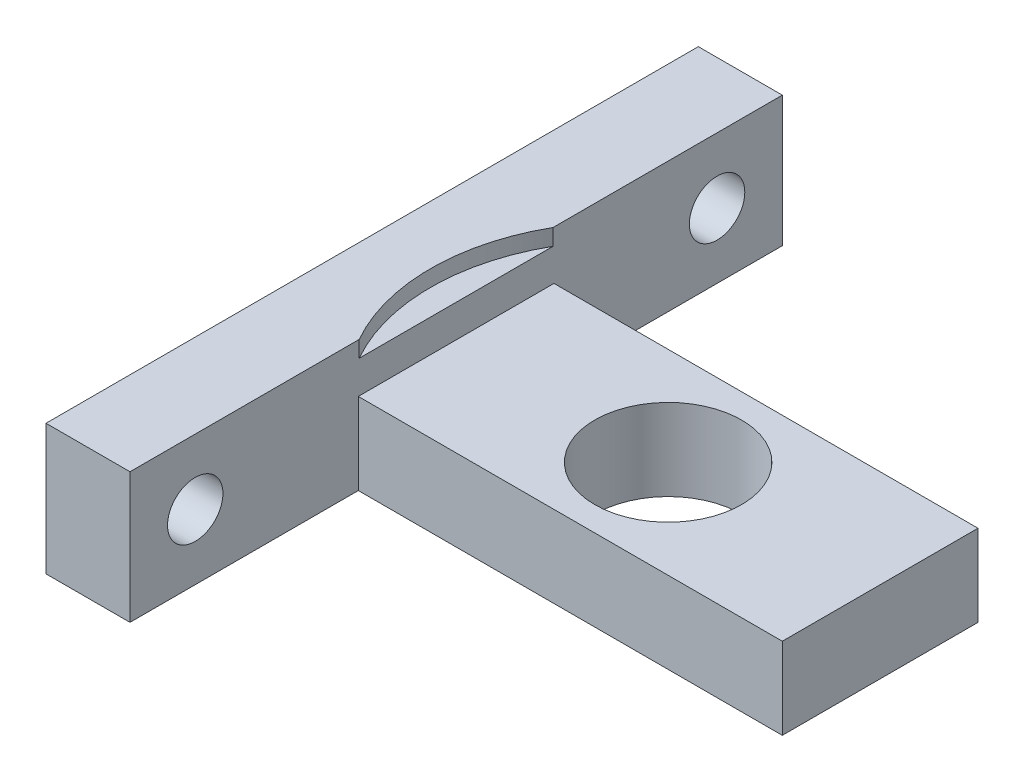
from build123d import *

# Parameters (mm, degrees)
CROQUIS1_W              = 5.15
CROQUIS1_H              = 40
SALIENTE_EXTRUIR1_DEPTH = 8
CROQUIS2_R              = 1.7
CORTAR_EXTRUIR1_DEPTH   = 11
CROQUIS3_W              = 26
CROQUIS3_H              = 12
CROQUIS3_R              = 4.5
SALIENTE_EXTRUIR2_DEPTH = 5
CROQUIS4_R              = 12
CORTAR_EXTRUIR2_DEPTH   = 1


with BuildPart() as part:
    # Croquis1 → Saliente-Extruir1 (new body)
    with BuildSketch(Plane(origin=(0, 0, 0), x_dir=(1, 0, 0), z_dir=(0, 1, 0))):
        Rectangle(CROQUIS1_W, CROQUIS1_H)
    extrude(amount=-SALIENTE_EXTRUIR1_DEPTH)

    # Croquis2 → Cortar-Extruir1 (cut)
    with BuildSketch(Plane(origin=(2.575, 0, 0), x_dir=(0, 0, -1), z_dir=(1, 0, 0))):
        with Locations((-16, -4)):
            Circle(CROQUIS2_R)
        with Locations((16, -4)):
            Circle(CROQUIS2_R)
    extrude(amount=-CORTAR_EXTRUIR1_DEPTH, mode=Mode.SUBTRACT)

    # Croquis3 → Saliente-Extruir2 (add)
    with BuildSketch(Plane(origin=(0, -8, 0), x_dir=(1, 0, 0), z_dir=(0, 1, 0))):
        with Locations((15.575, 0)):
            Rectangle(CROQUIS3_W, CROQUIS3_H)
        with Locations((15.575, 0)):
            Circle(CROQUIS3_R, mode=Mode.SUBTRACT)
    extrude(amount=SALIENTE_EXTRUIR2_DEPTH)

    # Croquis4 → Cortar-Extruir2 (cut)
    with BuildSketch(Plane(origin=(0, 0, 0), x_dir=(1, 0, 0), z_dir=(0, 1, 0))):
        with Locations((13, 0)):
            Circle(CROQUIS4_R)
    extrude(amount=-CORTAR_EXTRUIR2_DEPTH, mode=Mode.SUBTRACT)


solid = part.part
